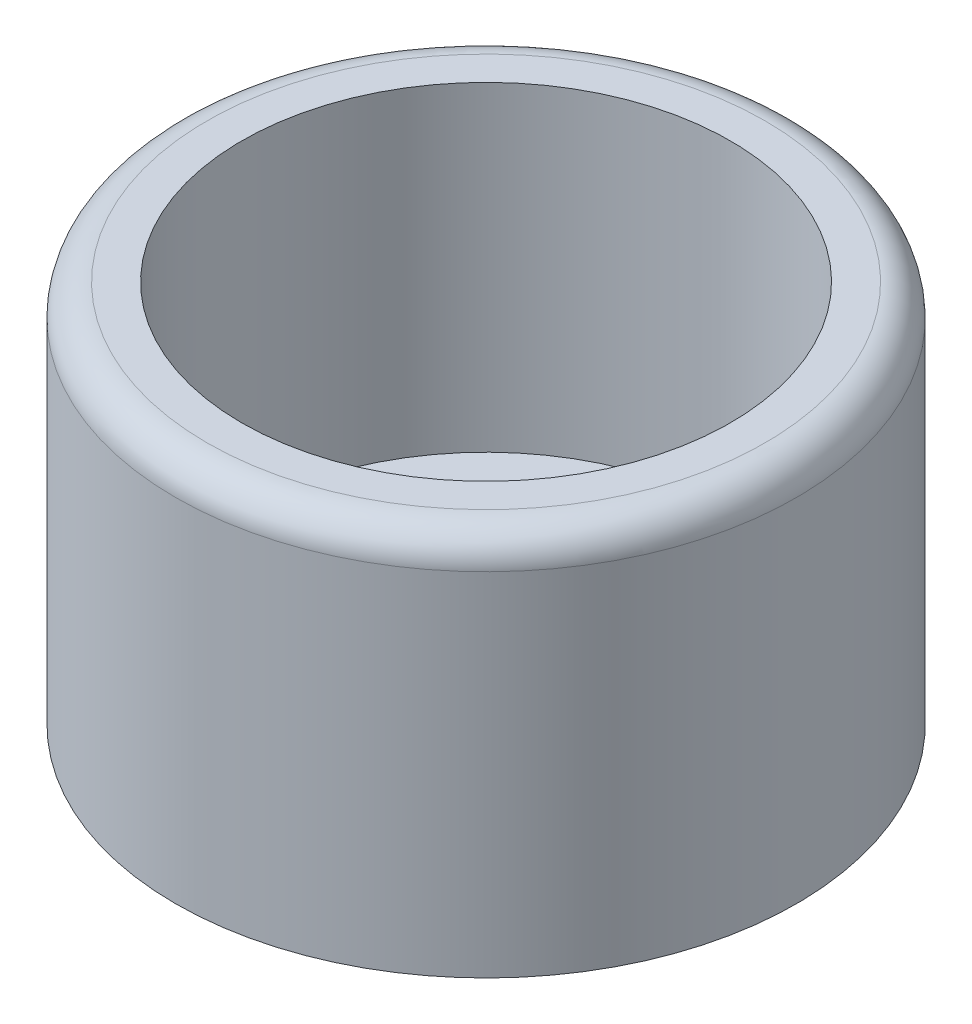
from build123d import *

# Parameters (mm, degrees)
SKETCH_1_R          = 4.925
EXTRUDE_1_DEPTH     = 6.08
SKETCH_2_R          = 3.875
CUT_EXTRUDE_1_DEPTH = 5.08
FILLET_1_R          = 0.5
CUT_EXTRUDE_2_DEPTH = 2


with BuildPart() as part:
    # Эскиз1 → Бобышка-Вытянуть1 (new body)
    with BuildSketch(Plane(origin=(0, 0, 0), x_dir=(1, 0, 0), z_dir=(0, 1, 0))):
        Circle(SKETCH_1_R)
    extrude(amount=EXTRUDE_1_DEPTH)

    # Эскиз2 → Вырез-Вытянуть1 (cut)
    with BuildSketch(Plane(origin=(0, 6.08, 0), x_dir=(1, 0, 0), z_dir=(0, 1, 0))):
        Circle(SKETCH_2_R)
    extrude(amount=-CUT_EXTRUDE_1_DEPTH, mode=Mode.SUBTRACT)

    # Скругление1
    fillet_1_edges = [part.edges().sort_by_distance(p)[0] for p in [
        (-4.925, 6.08, 0),
    ]]
    fillet(fillet_1_edges, radius=FILLET_1_R)

    # Эскиз3 → Вырез-Вытянуть2 (cut, through all)
    with BuildSketch(Plane(origin=(0, 1, 0), x_dir=(1, 0, 0), z_dir=(0, 1, 0))):
        with BuildLine():
            Line((2.875, 0.5), (0.5, 0.5))
            Line((0.5, 0.5), (0.5, 2.875))
            ThreePointArc((0.5, 2.875), (0, 3.375), (-0.5, 2.875))
            Line((-0.5, 2.875), (-0.5, 0.5))
            Line((-0.5, 0.5), (-2.875, 0.5))
            ThreePointArc((-2.875, 0.5), (-3.375, 0), (-2.875, -0.5))
            Line((-2.875, -0.5), (-0.5, -0.5))
            Line((-0.5, -0.5), (-0.5, -2.875))
            ThreePointArc((-0.5, -2.875), (0, -3.375), (0.5, -2.875))
            Line((0.5, -2.875), (0.5, -0.5))
            Line((0.5, -0.5), (2.875, -0.5))
            ThreePointArc((2.875, -0.5), (3.375, 0), (2.875, 0.5))
        make_face()
    extrude(amount=-CUT_EXTRUDE_2_DEPTH, mode=Mode.SUBTRACT)


solid = part.part
